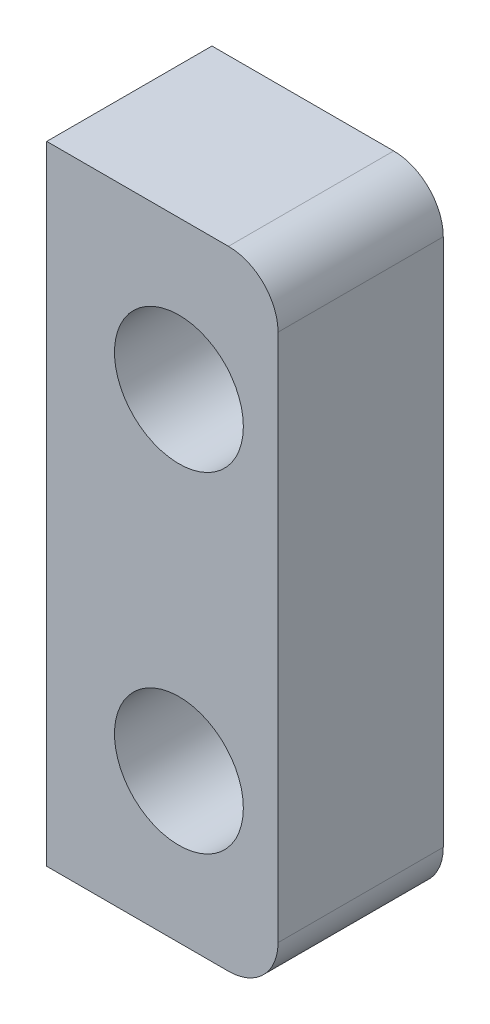
from build123d import *

# Parameters (mm, degrees)
SKETCH1_R           = 1.95
BOSS_EXTRUDE2_DEPTH = 5


with BuildPart() as part:
    # Sketch1 → Boss-Extrude2 (new body)
    with BuildSketch(Plane.XY):
        with BuildLine():
            Line((20, -9.5), (20, 9.5))
            Line((20, 9.5), (25.5, 9.5))
            ThreePointArc((25.5, 9.5), (26.560660172, 9.060660172), (27, 8))
            Line((27, 8), (27, -8))
            ThreePointArc((27, -8), (26.560660172, -9.060660172), (25.5, -9.5))
            Line((25.5, -9.5), (20, -9.5))
        make_face()
        with Locations((24, -5)):
            Circle(SKETCH1_R, mode=Mode.SUBTRACT)
        with Locations((24, 5)):
            Circle(SKETCH1_R, mode=Mode.SUBTRACT)
    extrude(amount=-BOSS_EXTRUDE2_DEPTH)


solid = part.part
